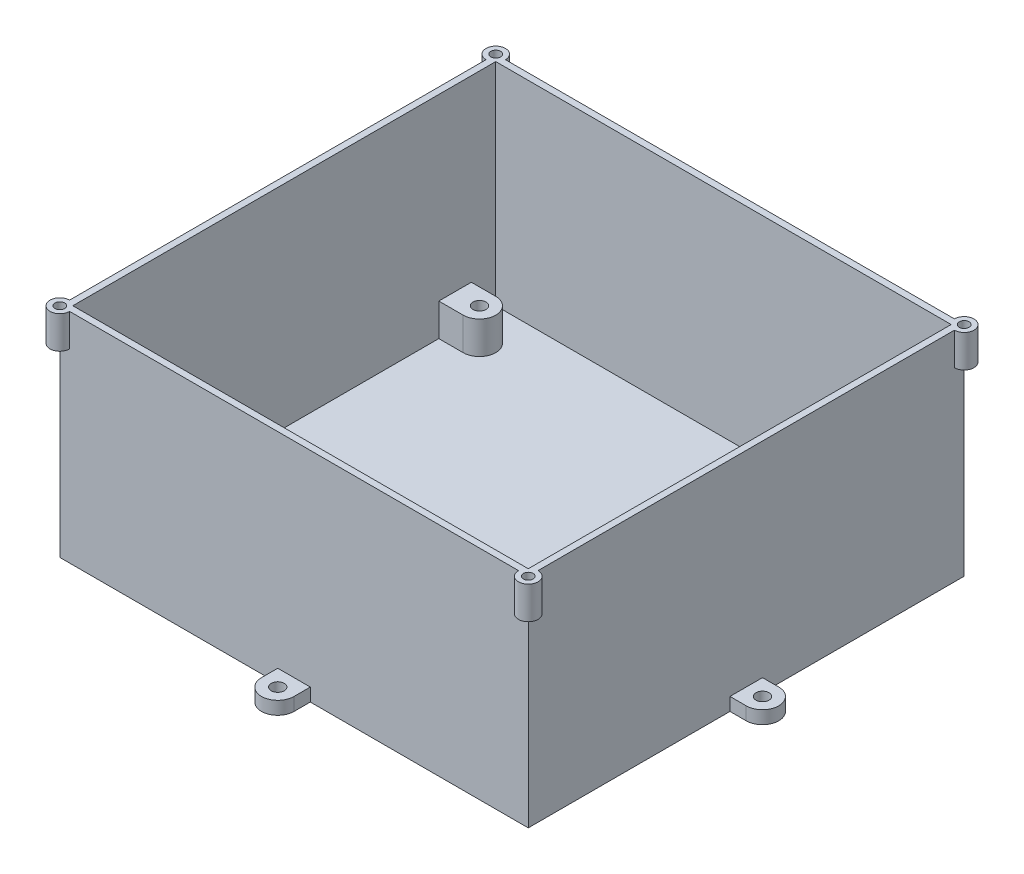
from build123d import *

# Parameters (mm, degrees)
SKETCH1_W            = 144
SKETCH1_H            = 134
SKETCH1_R            = 2
BOSS_EXTRUDE1_DEPTH  = 55
SKETCH2_R            = 2
CUT_EXTRUDE1_DEPTH   = 45
SKETCH3_W            = 144
SKETCH3_H            = 134
BOSS_EXTRUDE2_DEPTH  = 2
SKETCH5_R            = 2
BOSS_EXTRUDE4_DEPTH  = 4
SKETCH6_W            = 144
SKETCH6_H            = 134
SKETCH6_W_2          = 140
SKETCH6_H_2          = 130
BOSS_EXTRUDE5_DEPTH  = 10
BOSS_EXTRUDE11_DEPTH = 10
SKETCH12_R           = 1.5
CUT_EXTRUDE3_DEPTH   = 10


with BuildPart() as part:
    # Sketch1 → Boss-Extrude1 (new body)
    with BuildSketch(Plane(origin=(0, 0, 0), x_dir=(1, 0, 0), z_dir=(0, 1, 0))):
        Rectangle(SKETCH1_W, SKETCH1_H)
        with Locations((-62.5, 52.5)):
            Circle(SKETCH1_R, mode=Mode.SUBTRACT)
        with Locations((62.5, 52.5)):
            Circle(SKETCH1_R, mode=Mode.SUBTRACT)
        with Locations((-62.5, -52.5)):
            Circle(SKETCH1_R, mode=Mode.SUBTRACT)
        with Locations((62.5, -52.5)):
            Circle(SKETCH1_R, mode=Mode.SUBTRACT)
        with BuildLine():
            Line((-70, 65), (70, 65))
            Line((70, 65), (70, 57.5))
            Line((70, 57.5), (62.5, 57.5))
            ThreePointArc((62.5, 57.5), (57.5, 52.5), (62.5, 47.5))
            Line((62.5, 47.5), (70, 47.5))
            Line((70, 47.5), (70, -47.5))
            Line((70, -47.5), (62.5, -47.5))
            ThreePointArc((62.5, -47.5), (57.5, -52.5), (62.5, -57.5))
            Line((62.5, -57.5), (70, -57.5))
            Line((70, -57.5), (70, -65))
            Line((70, -65), (-70, -65))
            Line((-70, -65), (-70, -57.5))
            Line((-70, -57.5), (-62.5, -57.5))
            ThreePointArc((-62.5, -57.5), (-57.5, -52.5), (-62.5, -47.5))
            Line((-62.5, -47.5), (-70, -47.5))
            Line((-70, -47.5), (-70, 47.5))
            Line((-70, 47.5), (-62.5, 47.5))
            ThreePointArc((-62.5, 47.5), (-57.5, 52.5), (-62.5, 57.5))
            Line((-62.5, 57.5), (-70, 57.5))
            Line((-70, 57.5), (-70, 65))
        make_face(mode=Mode.SUBTRACT)
    extrude(amount=BOSS_EXTRUDE1_DEPTH)

    # Sketch2 → Cut-Extrude1 (cut)
    with BuildSketch(Plane(origin=(0, 55, 0), x_dir=(1, 0, 0), z_dir=(0, 1, 0))):
        with BuildLine():
            Line((-70, -47.5), (-62.5, -47.5))
            ThreePointArc((-62.5, -47.5), (-57.5, -52.5), (-62.5, -57.5))
            Line((-62.5, -57.5), (-70, -57.5))
            Line((-70, -57.5), (-70, -47.5))
        make_face()
        with Locations((-62.5, -52.5)):
            Circle(SKETCH2_R, mode=Mode.SUBTRACT)
        with BuildLine():
            Line((70, -57.5), (62.5, -57.5))
            ThreePointArc((62.5, -57.5), (57.5, -52.5), (62.5, -47.5))
            Line((62.5, -47.5), (70, -47.5))
            Line((70, -47.5), (70, -57.5))
        make_face()
        with Locations((62.5, -52.5)):
            Circle(SKETCH2_R, mode=Mode.SUBTRACT)
        with BuildLine():
            Line((70, 47.5), (62.5, 47.5))
            ThreePointArc((62.5, 47.5), (57.5, 52.5), (62.5, 57.5))
            Line((62.5, 57.5), (70, 57.5))
            Line((70, 57.5), (70, 47.5))
        make_face()
        with Locations((62.5, 52.5)):
            Circle(SKETCH2_R, mode=Mode.SUBTRACT)
        with BuildLine():
            Line((-62.5, 47.5), (-70, 47.5))
            Line((-70, 47.5), (-70, 57.5))
            Line((-70, 57.5), (-62.5, 57.5))
            ThreePointArc((-62.5, 57.5), (-57.5, 52.5), (-62.5, 47.5))
        make_face()
        with Locations((-62.5, 52.5)):
            Circle(SKETCH2_R, mode=Mode.SUBTRACT)
    extrude(amount=-CUT_EXTRUDE1_DEPTH, mode=Mode.SUBTRACT)

    # Sketch3 → Boss-Extrude2 (add)
    with BuildSketch(Plane.XZ):
        Rectangle(SKETCH3_W, SKETCH3_H)
    extrude(amount=BOSS_EXTRUDE2_DEPTH)

    # Sketch5 → Boss-Extrude4 (add)
    with BuildSketch(Plane.XZ.offset(2)):
        with BuildLine():
            Line((-70, -5), (-70, 5))
            Line((-70, 5), (-77, 5))
            ThreePointArc((-77, 5), (-82, 0), (-77, -5))
            Line((-77, -5), (-70, -5))
        make_face()
        with Locations((-77, 0)):
            Circle(SKETCH5_R, mode=Mode.SUBTRACT)
        with BuildLine():
            Line((5, -72), (5, -65))
            Line((5, -65), (-5, -65))
            Line((-5, -65), (-5, -72))
            ThreePointArc((-5, -72), (0, -77), (5, -72))
        make_face()
        with Locations((0, -72)):
            Circle(SKETCH5_R, mode=Mode.SUBTRACT)
        with BuildLine():
            Line((70, -5), (70, 5))
            Line((70, 5), (77, 5))
            ThreePointArc((77, 5), (82, 0), (77, -5))
            Line((77, -5), (70, -5))
        make_face()
        with Locations((77, 0)):
            Circle(SKETCH5_R, mode=Mode.SUBTRACT)
        with BuildLine():
            Line((-5, 65), (5, 65))
            Line((5, 65), (5, 72))
            ThreePointArc((5, 72), (0, 77), (-5, 72))
            Line((-5, 72), (-5, 65))
        make_face()
        with Locations((0, 72)):
            Circle(SKETCH5_R, mode=Mode.SUBTRACT)
    extrude(amount=-BOSS_EXTRUDE4_DEPTH)

    # Sketch6 → Boss-Extrude5 (add)
    with BuildSketch(Plane(origin=(0, 55, 0), x_dir=(1, 0, 0), z_dir=(0, 1, 0))):
        Rectangle(SKETCH6_W, SKETCH6_H)
        Rectangle(SKETCH6_W_2, SKETCH6_H_2, mode=Mode.SUBTRACT)
    extrude(amount=BOSS_EXTRUDE5_DEPTH)

    # Sketch11 → Boss-Extrude11 (add)
    with BuildSketch(Plane(origin=(0, 65, 0), x_dir=(1, 0, 0), z_dir=(0, 1, 0))):
        with BuildLine():
            ThreePointArc((-69, 67), (-74.121320344, 69.121320344), (-72, 64))
            Line((-72, 64), (-72, 65.5))
            ThreePointArc((-72, 65.5), (-73.060660172, 68.060660172), (-70.5, 67))
            Line((-70.5, 67), (-69, 67))
        make_face()
        with BuildLine():
            Line((72, 65.5), (72, 64))
            ThreePointArc((72, 64), (74.121320344, 69.121320344), (69, 67))
            Line((69, 67), (70.5, 67))
            ThreePointArc((70.5, 67), (72, 68.5), (73.5, 67))
            ThreePointArc((73.5, 67), (73.060660172, 65.939339828), (72, 65.5))
        make_face()
        with BuildLine():
            Line((70.5, -67), (69, -67))
            ThreePointArc((69, -67), (74.121320344, -69.121320344), (72, -64))
            Line((72, -64), (72, -65.5))
            ThreePointArc((72, -65.5), (73.060660172, -65.939339828), (73.5, -67))
            ThreePointArc((73.5, -67), (72, -68.5), (70.5, -67))
        make_face()
        with BuildLine():
            Line((-69, -67), (-70.5, -67))
            ThreePointArc((-70.5, -67), (-73.060660172, -68.060660172), (-72, -65.5))
            Line((-72, -65.5), (-72, -64))
            ThreePointArc((-72, -64), (-74.121320344, -69.121320344), (-69, -67))
        make_face()
    extrude(amount=-BOSS_EXTRUDE11_DEPTH)

    # Sketch12 → Cut-Extrude3 (cut)
    with BuildSketch(Plane(origin=(0, 65, 0), x_dir=(1, 0, 0), z_dir=(0, 1, 0))):
        with Locations((-72, 67)):
            Circle(SKETCH12_R)
        with Locations((72, 67)):
            Circle(SKETCH12_R)
        with Locations((72, -67)):
            Circle(SKETCH12_R)
        with Locations((-72, -67)):
            Circle(SKETCH12_R)
    extrude(amount=-CUT_EXTRUDE3_DEPTH, mode=Mode.SUBTRACT)


solid = part.part
